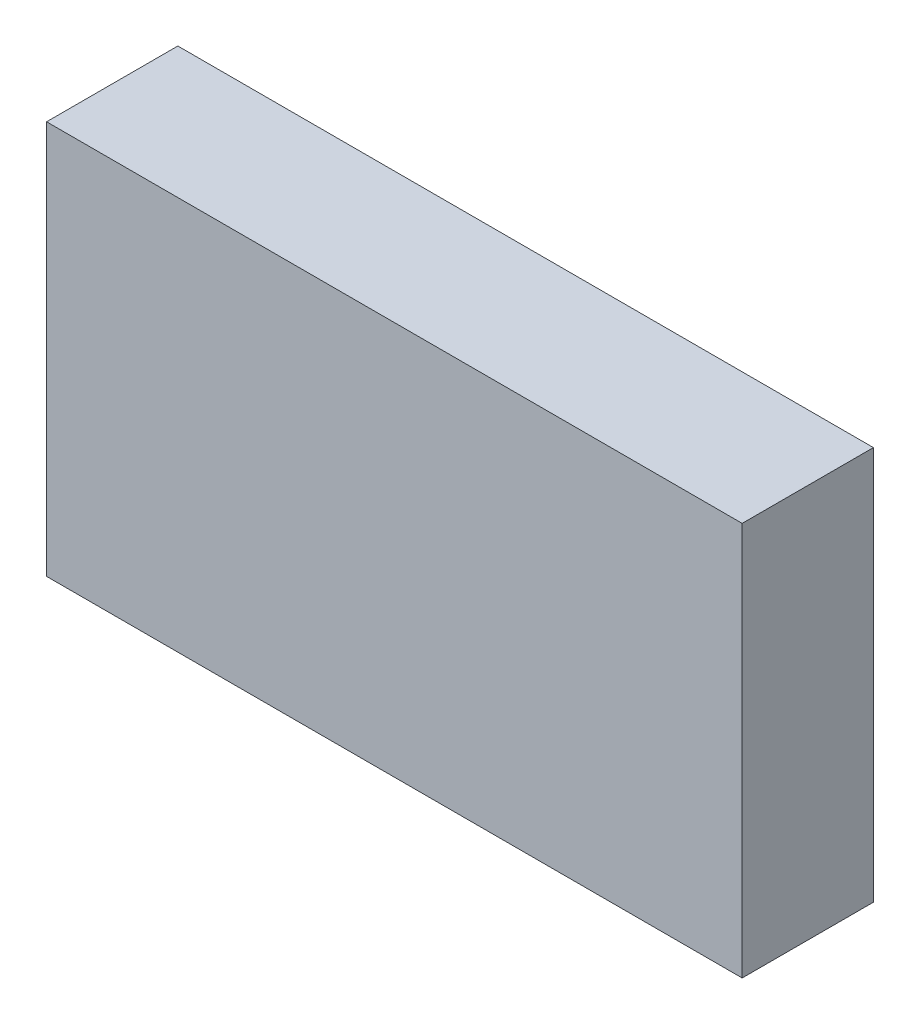
from build123d import *

# Parameters (mm, degrees)
CROQUIS1_W              = 53
CROQUIS1_H              = 30
SALIENTE_EXTRUIR1_DEPTH = 10


with BuildPart() as part:
    # Croquis1 → Saliente-Extruir1 (new body)
    with BuildSketch(Plane.XY):
        Rectangle(CROQUIS1_W, CROQUIS1_H)
    extrude(amount=SALIENTE_EXTRUIR1_DEPTH)


solid = part.part
